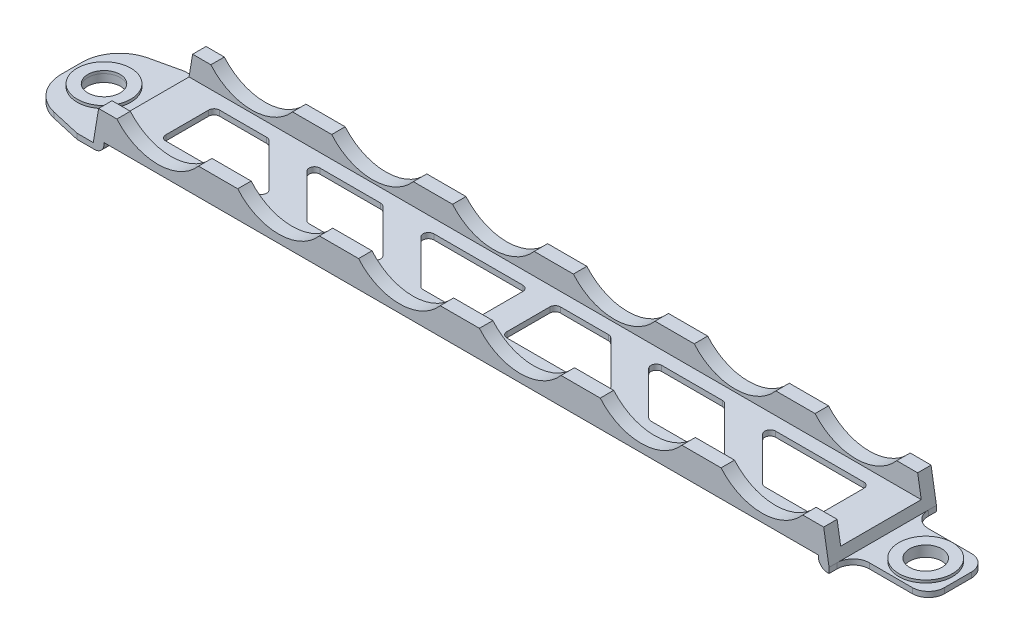
from build123d import *

# Parameters (mm, degrees)
SKETCH1_W           = 165
SKETCH1_H           = 20
EXTRUDE1_DEPTH      = 7
SKETCH2_W           = 165
SKETCH2_H           = 15
CUT_EXTRUDE2_DEPTH  = 4
CUT_EXTRUDE3_REACH  = 22
SKETCH3_W           = 22.076838398
SKETCH3_H           = 14.597093791
SKETCH3_W_2         = 22.076838397
SKETCH3_W_3         = 133
SKETCH3_H_2         = 13.03678166
SKETCH4_R           = 10
CUT_EXTRUDE4_DEPTH  = 21
LPATTERN1_COUNT     = 6
LPATTERN1_PITCH     = 22.5
CUT_EXTRUDE5_DEPTH  = 21
SKETCH6_R           = 5
SKETCH6_R_2         = 3
EXTRUDE2_DEPTH      = 0.5
CUT_EXTRUDE6_REACH  = 3
SKETCH7_R           = 3.099241347
CUT_EXTRUDE7_START  = -1
CUT_EXTRUDE7_DEPTH  = 1
SKETCH9_R           = 5
SKETCH9_R_2         = 3.099241347
EXTRUDE3_DEPTH      = 0.5
CUT_EXTRUDE8_REACH  = 3.5
SKETCH10_R          = 3
CUT_EXTRUDE9_START  = -1
CUT_EXTRUDE9_DEPTH  = 1
SKETCH12_R          = 5
SKETCH12_R_2        = 3
EXTRUDE4_DEPTH      = 0.5
SKETCH13_R          = 5
SKETCH13_R_2        = 3
EXTRUDE5_DEPTH      = 0.5
CUT_EXTRUDE10_REACH = 5.5
FILLET1_R           = 1.75


with BuildPart() as part:
    # Sketch1 → Extrude1 (new body)
    with BuildSketch(Plane(origin=(0, 0, 0), x_dir=(1, 0, 0), z_dir=(0, 1, 0))):
        with Locations((6.635535007, -6.684478203)):
            Rectangle(SKETCH1_W, SKETCH1_H)
    extrude(amount=EXTRUDE1_DEPTH)

    # Sketch2 → Cut-Extrude2 (cut)
    with BuildSketch(Plane(origin=(0, 7, 0), x_dir=(-1, 0, 0), z_dir=(0, 1, 0))):
        with Locations((-6.635535007, 6.684478203)):
            Rectangle(SKETCH2_W, SKETCH2_H)
    extrude(amount=-CUT_EXTRUDE2_DEPTH, mode=Mode.SUBTRACT)

    # Sketch3 → Cut-Extrude3 (cut, up to next)
    with BuildSketch(Plane.XY.offset(16.684478203), mode=Mode.PRIVATE) as cut_extrude3_sk1:
        with Locations((-72.902884192, 8.298546895)):
            Rectangle(SKETCH3_W, SKETCH3_H)
    cut_extrude3_tool1 = extrude(cut_extrude3_sk1.sketch, amount=-CUT_EXTRUDE3_REACH, mode=Mode.PRIVATE) & part.part
    add(cut_extrude3_tool1.solids().sort_by_distance((-72.902884, 8.298547, 16.684478))[0], mode=Mode.SUBTRACT)
    # Sketch3 → Cut-Extrude3 (cut, up to next)
    with BuildSketch(Plane.XY.offset(16.684478203), mode=Mode.PRIVATE) as cut_extrude3_sk2:
        with Locations((86.173954205, 8.298546895)):
            Rectangle(SKETCH3_W_2, SKETCH3_H)
    cut_extrude3_tool2 = extrude(cut_extrude3_sk2.sketch, amount=-CUT_EXTRUDE3_REACH, mode=Mode.PRIVATE) & part.part
    add(cut_extrude3_tool2.solids().sort_by_distance((86.173954, 8.298547, 16.684478))[0], mode=Mode.SUBTRACT)
    # Sketch3 → Cut-Extrude3 (cut, up to next)
    with BuildSketch(Plane.XY.offset(16.684478203), mode=Mode.PRIVATE) as cut_extrude3_sk3:
        with Locations((6.635535007, -4.51839083)):
            Rectangle(SKETCH3_W_3, SKETCH3_H_2)
    cut_extrude3_tool3 = extrude(cut_extrude3_sk3.sketch, amount=-CUT_EXTRUDE3_REACH, mode=Mode.PRIVATE) & part.part
    add(cut_extrude3_tool3.solids().sort_by_distance((6.635535, -4.518391, 16.684478))[0], mode=Mode.SUBTRACT)

    # Sketch4 → Cut-Extrude4 (cut, through all)
    with BuildSketch(Plane.XY.offset(16.684478203)):
        with Locations((-49.864464993, 13.5)):
            Circle(SKETCH4_R)
    cut_extrude4 = extrude(amount=-CUT_EXTRUDE4_DEPTH, mode=Mode.SUBTRACT)

    # LPattern1: Cut-Extrude4 ×6
    with Locations(*[(i * LPATTERN1_PITCH, 0, 0) for i in range(1, LPATTERN1_COUNT)]):
        add(cut_extrude4, mode=Mode.SUBTRACT)

    # Sketch5 → Cut-Extrude5 (cut, through all)
    with BuildSketch(Plane.XY.offset(16.684478203)):
        Polygon((-61.864464993, 1), (-60.864418693, 7), (-64.440232493, 7), align=None)
        Polygon((75.135535007, 1), (74.135535007, 7), (77.920607538, 7), align=None)
    extrude(amount=-CUT_EXTRUDE5_DEPTH, mode=Mode.SUBTRACT)

    # Sketch6 → Extrude2 (add)
    with BuildSketch(Plane(origin=(0, 1, 0), x_dir=(-1, 0, 0), z_dir=(0, 1, 0))):
        with Locations(Location((69.864464993, 6.684478203, 0), (0, 0, 270))):  # turned: the seam where the file's is
            Circle(SKETCH6_R)
        with Locations(Location((69.864464993, 6.684478203, 0), (0, 0, 90))):  # turned: the seam where the file's is
            Circle(SKETCH6_R_2, mode=Mode.SUBTRACT)
    extrude(amount=EXTRUDE2_DEPTH)

    # Sketch7 → Cut-Extrude6 (cut, up to next)
    with BuildSketch(Plane(origin=(0, 1, 0), x_dir=(-1, 0, 0), z_dir=(0, 1, 0)), mode=Mode.PRIVATE) as cut_extrude6_sk1:
        with Locations(Location((69.864464993, 6.684478203, 0), (0, 0, 90))):  # turned: the seam where the file's is
            Circle(SKETCH7_R)
    cut_extrude6_tool1 = extrude(cut_extrude6_sk1.sketch, amount=-CUT_EXTRUDE6_REACH, mode=Mode.PRIVATE) & part.part
    add(cut_extrude6_tool1.solids().sort_by_distance((-69.864465, 1, 6.684478))[0], mode=Mode.SUBTRACT)

    # Sketch8 → Cut-Extrude7 (cut)
    with BuildSketch(Plane(origin=(0, 1, 0), x_dir=(-1, 0, 0), z_dir=(0, 1, 0)).offset(CUT_EXTRUDE7_START)):
        with BuildLine():
            Line((64.864464993, -3.315521797), (75.864464993, -11.455388842))
            Line((75.864464993, -11.455388842), (88.934533006, -0.815521797))
            Line((88.934533006, -0.815521797), (80.368724017, 25.989433313))
            Line((80.368724017, 25.989433313), (64.864464993, 16.684478203))
            Line((64.864464993, 16.684478203), (70.415812719, 15.422808266))
            ThreePointArc((70.415812719, 15.422808266), (74.335270879, 12.963831786), (75.864464993, 8.596878275))
            Line((75.864464993, 8.596878275), (75.864464993, 4.772078132))
            ThreePointArc((75.864464993, 4.772078132), (74.335270879, 0.405124621), (70.415812719, -2.053851859))
            Line((70.415812719, -2.053851859), (64.864464993, -3.315521797))
        make_face()
    extrude(amount=CUT_EXTRUDE7_DEPTH, mode=Mode.SUBTRACT)

    # Sketch9 → Extrude3 (add)
    with BuildSketch(Plane.XZ):
        with Locations(Location((-69.864464993, 6.684478203, 0), (0, 0, 270))):  # turned: the seam where the file's is
            Circle(SKETCH9_R)
        with Locations(Location((-69.864464993, 6.684478203, 0), (0, 0, 90))):  # turned: the seam where the file's is
            Circle(SKETCH9_R_2, mode=Mode.SUBTRACT)
    extrude(amount=EXTRUDE3_DEPTH)

    # Sketch10 → Cut-Extrude8 (cut, up to next)
    with BuildSketch(Plane(origin=(0, 1, 0), x_dir=(-1, 0, 0), z_dir=(0, 1, 0)), mode=Mode.PRIVATE) as cut_extrude8_sk1:
        with Locations(Location((-83.135535007, 6.684478203, 0), (0, 0, 90))):  # turned: the seam where the file's is
            Circle(SKETCH10_R)
    cut_extrude8_tool1 = extrude(cut_extrude8_sk1.sketch, amount=-CUT_EXTRUDE8_REACH, mode=Mode.PRIVATE) & part.part
    add(cut_extrude8_tool1.solids().sort_by_distance((83.135535, 1, 6.684478))[0], mode=Mode.SUBTRACT)

    # Sketch11 → Cut-Extrude9 (cut)
    with BuildSketch(Plane(origin=(0, 1, 0), x_dir=(-1, 0, 0), z_dir=(0, 1, 0)).offset(CUT_EXTRUDE9_START)):
        with BuildLine():
            Line((-75.135535007, -8.660651572), (-98.596814131, -8.660651572))
            Line((-98.596814131, -8.660651572), (-98.596814131, 22.029607978))
            Line((-98.596814131, 22.029607978), (-75.135535007, 22.029607978))
            Line((-75.135535007, 22.029607978), (-75.135535007, 15.184478203))
            ThreePointArc((-75.135535007, 15.184478203), (-76.014214663, 13.06315786), (-78.135535007, 12.184478203))
            Line((-78.135535007, 12.184478203), (-86.135535007, 12.184478203))
            ThreePointArc((-86.135535007, 12.184478203), (-88.25685535, 11.305798547), (-89.135535007, 9.184478203))
            Line((-89.135535007, 9.184478203), (-89.135535007, 4.184478203))
            ThreePointArc((-89.135535007, 4.184478203), (-88.25685535, 2.06315786), (-86.135535007, 1.184478203))
            Line((-86.135535007, 1.184478203), (-78.135535007, 1.184478203))
            ThreePointArc((-78.135535007, 1.184478203), (-76.014214663, 0.305798547), (-75.135535007, -1.815521797))
            Line((-75.135535007, -1.815521797), (-75.135535007, -8.660651572))
        make_face()
    extrude(amount=CUT_EXTRUDE9_DEPTH, mode=Mode.SUBTRACT)

    # Sketch12 → Extrude4 (add)
    with BuildSketch(Plane(origin=(0, 1, 0), x_dir=(-1, 0, 0), z_dir=(0, 1, 0))):
        with Locations(Location((-83.135535007, 6.684478203, 0), (0, 0, 270))):  # turned: the seam where the file's is
            Circle(SKETCH12_R)
        with Locations(Location((-83.135535007, 6.684478203, 0), (0, 0, 90))):  # turned: the seam where the file's is
            Circle(SKETCH12_R_2, mode=Mode.SUBTRACT)
    extrude(amount=EXTRUDE4_DEPTH)

    # Sketch13 → Extrude5 (add)
    with BuildSketch(Plane.XZ):
        with Locations(Location((83.135535007, 6.684478203, 0), (0, 0, 270))):  # turned: the seam where the file's is
            Circle(SKETCH13_R)
        with Locations(Location((83.135535007, 6.684478203, 0), (0, 0, 90))):  # turned: the seam where the file's is
            Circle(SKETCH13_R_2, mode=Mode.SUBTRACT)
    extrude(amount=EXTRUDE5_DEPTH)

    # Sketch14 → Cut-Extrude10 (cut, up to next)
    with BuildSketch(Plane(origin=(0, 3, 0), x_dir=(-1, 0, 0), z_dir=(0, 1, 0)), mode=Mode.PRIVATE) as cut_extrude10_sk1:
        with BuildLine():
            Line((53.364464993, 1.684478203), (44.562949803, 1.684478203))
            ThreePointArc((44.562949803, 1.684478203), (44.180266371, 1.760598671), (43.855843022, 1.977371422))
            Line((43.855843022, 1.977371422), (35.855843022, 9.977371422))
            ThreePointArc((35.855843022, 9.977371422), (35.639070271, 11.067161636), (36.562949803, 11.684478203))
            Line((36.562949803, 11.684478203), (53.364464993, 11.684478203))
            ThreePointArc((53.364464993, 11.684478203), (54.071571775, 11.391584985), (54.364464993, 10.684478203))
            Line((54.364464993, 10.684478203), (54.364464993, 2.684478203))
            ThreePointArc((54.364464993, 2.684478203), (54.071571775, 1.977371422), (53.364464993, 1.684478203))
        make_face()
    cut_extrude10_tool1 = extrude(cut_extrude10_sk1.sketch, amount=-CUT_EXTRUDE10_REACH, mode=Mode.PRIVATE) & part.part
    add(cut_extrude10_tool1.solids().sort_by_distance((-46.553759, 3, 7.201578))[0], mode=Mode.SUBTRACT)
    # Sketch14 → Cut-Extrude10 (cut, up to next)
    with BuildSketch(Plane(origin=(0, 3, 0), x_dir=(-1, 0, 0), z_dir=(0, 1, 0)), mode=Mode.PRIVATE) as cut_extrude10_sk2:
        with BuildLine():
            Line((-67.635535007, 2.684478203), (-67.635535007, 10.684478203))
            ThreePointArc((-67.635535007, 10.684478203), (-67.342641788, 11.391584985), (-66.635535007, 11.684478203))
            Line((-66.635535007, 11.684478203), (-58.189358876, 11.684478203))
            ThreePointArc((-58.189358876, 11.684478203), (-57.806675443, 11.608357736), (-57.482252095, 11.391584985))
            Line((-57.482252095, 11.391584985), (-49.482252095, 3.391584985))
            ThreePointArc((-49.482252095, 3.391584985), (-49.265479343, 2.301794771), (-50.189358876, 1.684478203))
            Line((-50.189358876, 1.684478203), (-66.635535007, 1.684478203))
            ThreePointArc((-66.635535007, 1.684478203), (-67.342641788, 1.977371422), (-67.635535007, 2.684478203))
        make_face()
    cut_extrude10_tool2 = extrude(cut_extrude10_sk2.sketch, amount=-CUT_EXTRUDE10_REACH, mode=Mode.PRIVATE) & part.part
    add(cut_extrude10_tool2.solids().sort_by_distance((59.99659, 3, 6.154872))[0], mode=Mode.SUBTRACT)
    # Sketch14 → Cut-Extrude10 (cut, up to next)
    with BuildSketch(Plane(origin=(0, 3, 0), x_dir=(-1, 0, 0), z_dir=(0, 1, 0)), mode=Mode.PRIVATE) as cut_extrude10_sk3:
        with BuildLine():
            Line((-4.135535007, 2.684478203), (-4.135535007, 10.684478203))
            ThreePointArc((-4.135535007, 10.684478203), (-3.842641788, 11.391584985), (-3.135535007, 11.684478203))
            Line((-3.135535007, 11.684478203), (5.450251431, 11.684478203))
            ThreePointArc((5.450251431, 11.684478203), (5.832934863, 11.608357736), (6.157358212, 11.391584985))
            Line((6.157358212, 11.391584985), (14.157358212, 3.391584985))
            ThreePointArc((14.157358212, 3.391584985), (14.374130964, 2.301794771), (13.450251431, 1.684478203))
            Line((13.450251431, 1.684478203), (-3.135535007, 1.684478203))
            ThreePointArc((-3.135535007, 1.684478203), (-3.842641788, 1.977371422), (-4.135535007, 2.684478203))
        make_face()
    cut_extrude10_tool3 = extrude(cut_extrude10_sk3.sketch, amount=-CUT_EXTRUDE10_REACH, mode=Mode.PRIVATE) & part.part
    add(cut_extrude10_tool3.solids().sort_by_distance((-3.57086, 3, 6.159857))[0], mode=Mode.SUBTRACT)
    # Sketch14 → Cut-Extrude10 (cut, up to next)
    with BuildSketch(Plane(origin=(0, 3, 0), x_dir=(-1, 0, 0), z_dir=(0, 1, 0)), mode=Mode.PRIVATE) as cut_extrude10_sk4:
        with BuildLine():
            Line((-9.135535007, 2.684478203), (-9.135535007, 10.684478203))
            ThreePointArc((-9.135535007, 10.684478203), (-9.428428225, 11.391584985), (-10.135535007, 11.684478203))
            Line((-10.135535007, 11.684478203), (-27.076660504, 11.684478203))
            ThreePointArc((-27.076660504, 11.684478203), (-28.000540036, 11.067161636), (-27.783767285, 9.977371422))
            Line((-27.783767285, 9.977371422), (-19.783767285, 1.977371422))
            ThreePointArc((-19.783767285, 1.977371422), (-19.459343936, 1.760598671), (-19.076660504, 1.684478203))
            Line((-19.076660504, 1.684478203), (-10.135535007, 1.684478203))
            ThreePointArc((-10.135535007, 1.684478203), (-9.428428225, 1.977371422), (-9.135535007, 2.684478203))
        make_face()
    cut_extrude10_tool4 = extrude(cut_extrude10_sk4.sketch, amount=-CUT_EXTRUDE10_REACH, mode=Mode.PRIVATE) & part.part
    add(cut_extrude10_tool4.solids().sort_by_distance((17.013801, 3, 7.196824))[0], mode=Mode.SUBTRACT)
    # Sketch14 → Cut-Extrude10 (cut, up to next)
    with BuildSketch(Plane(origin=(0, 3, 0), x_dir=(-1, 0, 0), z_dir=(0, 1, 0)), mode=Mode.PRIVATE) as cut_extrude10_sk5:
        with BuildLine():
            Line((22.642639586, 1.977371422), (14.642639586, 9.977371422))
            ThreePointArc((14.642639586, 9.977371422), (14.425866835, 11.067161636), (15.349746368, 11.684478203))
            Line((15.349746368, 11.684478203), (26.663454867, 11.684478203))
            ThreePointArc((26.663454867, 11.684478203), (27.046138299, 11.608357736), (27.370561648, 11.391584985))
            Line((27.370561648, 11.391584985), (35.370561648, 3.391584985))
            ThreePointArc((35.370561648, 3.391584985), (35.587334399, 2.301794771), (34.663454867, 1.684478203))
            Line((34.663454867, 1.684478203), (23.349746368, 1.684478203))
            ThreePointArc((23.349746368, 1.684478203), (22.967062935, 1.760598671), (22.642639586, 1.977371422))
        make_face()
    cut_extrude10_tool5 = extrude(cut_extrude10_sk5.sketch, amount=-CUT_EXTRUDE10_REACH, mode=Mode.PRIVATE) & part.part
    add(cut_extrude10_tool5.solids().sort_by_distance((-25.006601, 3, 6.684478))[0], mode=Mode.SUBTRACT)
    # Sketch14 → Cut-Extrude10 (cut, up to next)
    with BuildSketch(Plane(origin=(0, 3, 0), x_dir=(-1, 0, 0), z_dir=(0, 1, 0)), mode=Mode.PRIVATE) as cut_extrude10_sk6:
        with BuildLine():
            Line((-28.269048659, 3.391584985), (-36.269048659, 11.391584985))
            ThreePointArc((-36.269048659, 11.391584985), (-36.593472008, 11.608357736), (-36.97615544, 11.684478203))
            Line((-36.97615544, 11.684478203), (-48.289863939, 11.684478203))
            ThreePointArc((-48.289863939, 11.684478203), (-49.213743472, 11.067161636), (-48.99697072, 9.977371422))
            Line((-48.99697072, 9.977371422), (-40.99697072, 1.977371422))
            ThreePointArc((-40.99697072, 1.977371422), (-40.672547372, 1.760598671), (-40.289863939, 1.684478203))
            Line((-40.289863939, 1.684478203), (-28.97615544, 1.684478203))
            ThreePointArc((-28.97615544, 1.684478203), (-28.052275908, 2.301794771), (-28.269048659, 3.391584985))
        make_face()
    cut_extrude10_tool6 = extrude(cut_extrude10_sk6.sketch, amount=-CUT_EXTRUDE10_REACH, mode=Mode.PRIVATE) & part.part
    add(cut_extrude10_tool6.solids().sort_by_distance((38.63301, 3, 6.684478))[0], mode=Mode.SUBTRACT)

    # Fillet1
    fillet1_edges = [part.edges().sort_by_distance(p)[0] for p in [
        (-59.864464993, 0, 6.684478203),
        (73.135535007, 0, 6.684478203),
    ]]
    fillet(fillet1_edges, radius=FILLET1_R)


solid = part.part
